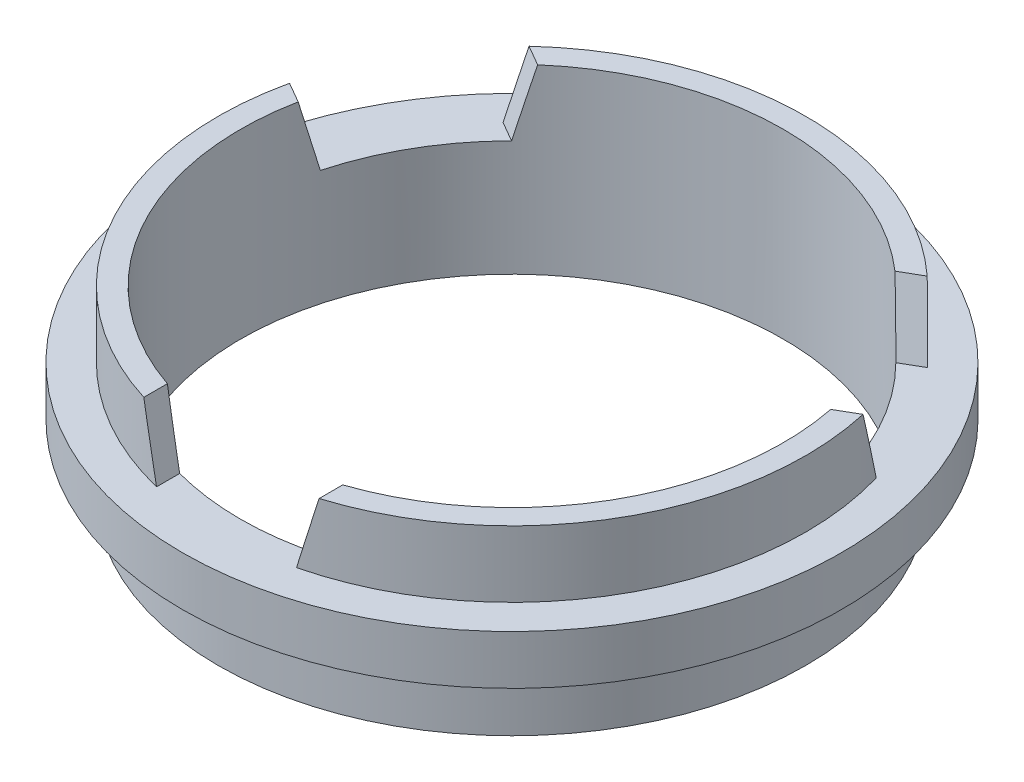
from build123d import *

# Parameters (mm, degrees)
SKETCH1_R               = 9.7
BOSS_EXTRUDE1_DEPTH     = 5.35
SKETCH2_R               = 9.7
SKETCH2_R_2             = 8.65
CUT_EXTRUDE1_DEPTH      = 1.95
SKETCH3_R               = 9.7
SKETCH3_R_2             = 8.65
CUT_EXTRUDE2_DEPTH      = 1.95
CUT_EXTRUDE3_DEPTH      = 2.95
CUT_EXTRUDE3_DEPTH_BACK = 1.95
SKETCH5_R               = 7.99
CUT_EXTRUDE4_DEPTH      = 6.35
CUT_EXTRUDE5_DEPTH      = 10.7
CIRPATTERN1_COUNT       = 3


with BuildPart() as part:
    # Sketch1 → Boss-Extrude1 (new body)
    with BuildSketch(Plane(origin=(0, 0, 0), x_dir=(1, 0, 0), z_dir=(0, 1, 0))):
        Circle(SKETCH1_R)
    extrude(amount=BOSS_EXTRUDE1_DEPTH)

    # Sketch2 → Cut-Extrude1 (cut)
    with BuildSketch(Plane(origin=(0, 5.35, 0), x_dir=(1, 0, 0), z_dir=(0, 1, 0))):
        Circle(SKETCH2_R)
        Circle(SKETCH2_R_2, mode=Mode.SUBTRACT)
    extrude(amount=-CUT_EXTRUDE1_DEPTH, mode=Mode.SUBTRACT)

    # Sketch3 → Cut-Extrude2 (cut)
    with BuildSketch(Plane.XZ):
        Circle(SKETCH3_R)
        Circle(SKETCH3_R_2, mode=Mode.SUBTRACT)
    extrude(amount=-CUT_EXTRUDE2_DEPTH, mode=Mode.SUBTRACT)

    # Sketch4 → Cut-Extrude3 (cut, two sides)
    with BuildSketch(Plane(origin=(0, 3.4, 0), x_dir=(1, 0, 0), z_dir=(0, 1, 0))) as cut_extrude3_sk:
        with BuildLine():
            Line((-35.407684365, 52.835510073), (-1.8, 9.531526635))
            ThreePointArc((-1.8, 9.531526635), (0, 8.65), (1.8, 9.531526635))
            Line((1.8, 9.531526635), (35.407684365, 52.835510073))
            Line((35.407684365, 52.835510073), (35.407684365, 162.466006376))
            Line((35.407684365, 162.466006376), (-35.407684365, 162.466006376))
            Line((-35.407684365, 162.466006376), (-35.407684365, 52.835510073))
        make_face()
    extrude(amount=CUT_EXTRUDE3_DEPTH, mode=Mode.SUBTRACT)
    extrude(cut_extrude3_sk.sketch, amount=-CUT_EXTRUDE3_DEPTH_BACK, mode=Mode.SUBTRACT)

    # Sketch5 → Cut-Extrude4 (cut, through all)
    with BuildSketch(Plane(origin=(0, 5.35, 0), x_dir=(1, 0, 0), z_dir=(0, 1, 0))):
        Circle(SKETCH5_R)
    extrude(amount=-CUT_EXTRUDE4_DEPTH, mode=Mode.SUBTRACT)

    # Sketch6 → Cut-Extrude5 (cut, through all)
    with BuildSketch(Plane.XY):
        Polygon((0, 3.4), (-2.06, 3.4), (-2.58, 5.35), (0, 5.35), (2.58, 5.35), (2.06, 3.4), align=None)
    cut_extrude5 = extrude(amount=CUT_EXTRUDE5_DEPTH, mode=Mode.SUBTRACT)

    # CirPattern1: Cut-Extrude5 ×3 about axis
    cirpattern1_axis = Axis((0, 0, 0), (0, 1, 0))
    for i in range(1, CIRPATTERN1_COUNT):
        add(cut_extrude5.rotate(cirpattern1_axis, i * 360 / CIRPATTERN1_COUNT), mode=Mode.SUBTRACT)


solid = part.part
